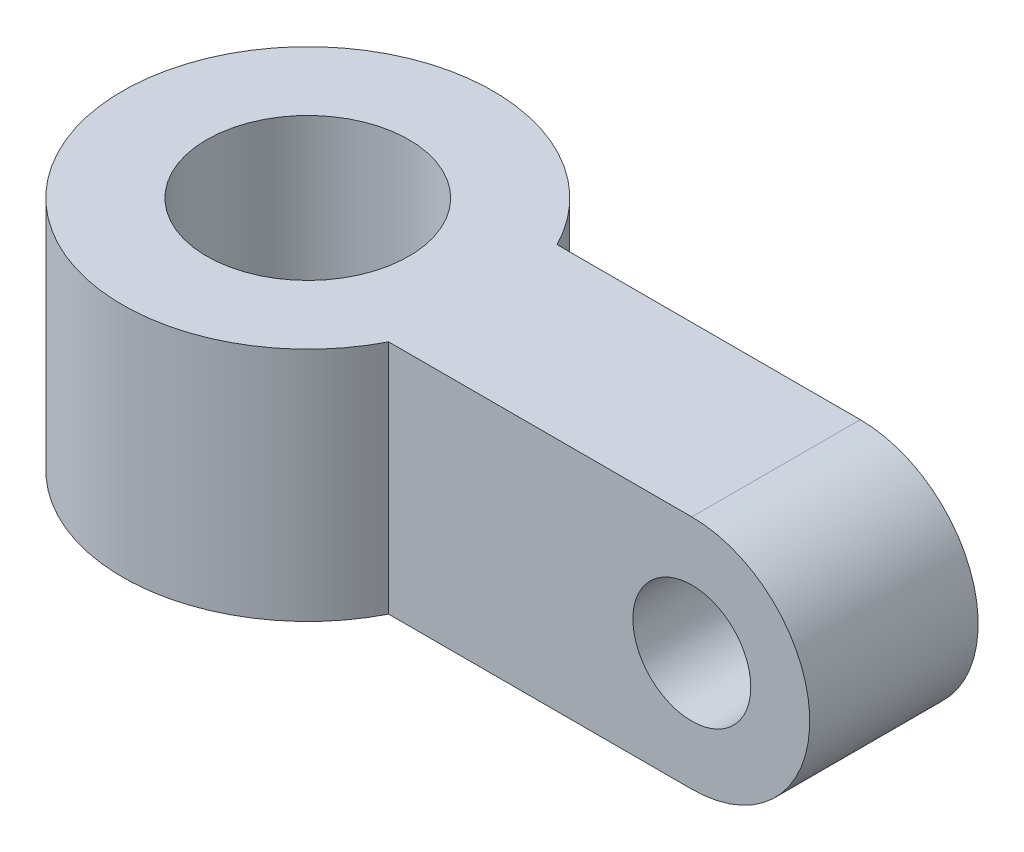
from build123d import *

# Parameters (mm, degrees)
ESBO_O1_R                = 1.75
RESSALTO_EXTRUS_O1_DEPTH = 5
ESBO_O2_R                = 3
RESSALTO_EXTRUS_O2_DEPTH = 7


with BuildPart() as part:
    # Esboço1 → Ressalto-extrusão1 (new body)
    with BuildSketch(Plane.XY):
        with BuildLine():
            Line((0, 3.5), (-6, 3.5))
            Line((-6, 3.5), (-6, -3.5))
            Line((-6, -3.5), (0, -3.5))
            ThreePointArc((0, -3.5), (3.5, 0), (0, 3.5))
        make_face()
        Circle(ESBO_O1_R, mode=Mode.SUBTRACT)
    extrude(amount=RESSALTO_EXTRUS_O1_DEPTH)

    # Esboço2 → Ressalto-extrusão2 (add)
    with BuildSketch(Plane(origin=(0, 3.5, 0), x_dir=(1, 0, 0), z_dir=(0, 1, 0))):
        with BuildLine():
            Line((-6, -5), (-6, 0))
            Line((-6, 0), (-9, 0))
            ThreePointArc((-9, 0), (-19.398979486, -2.5), (-9, -5))
            Line((-9, -5), (-6, -5))
        make_face()
        with Locations((-13.898979486, -2.5)):
            Circle(ESBO_O2_R, mode=Mode.SUBTRACT)
    extrude(amount=-RESSALTO_EXTRUS_O2_DEPTH)


solid = part.part
